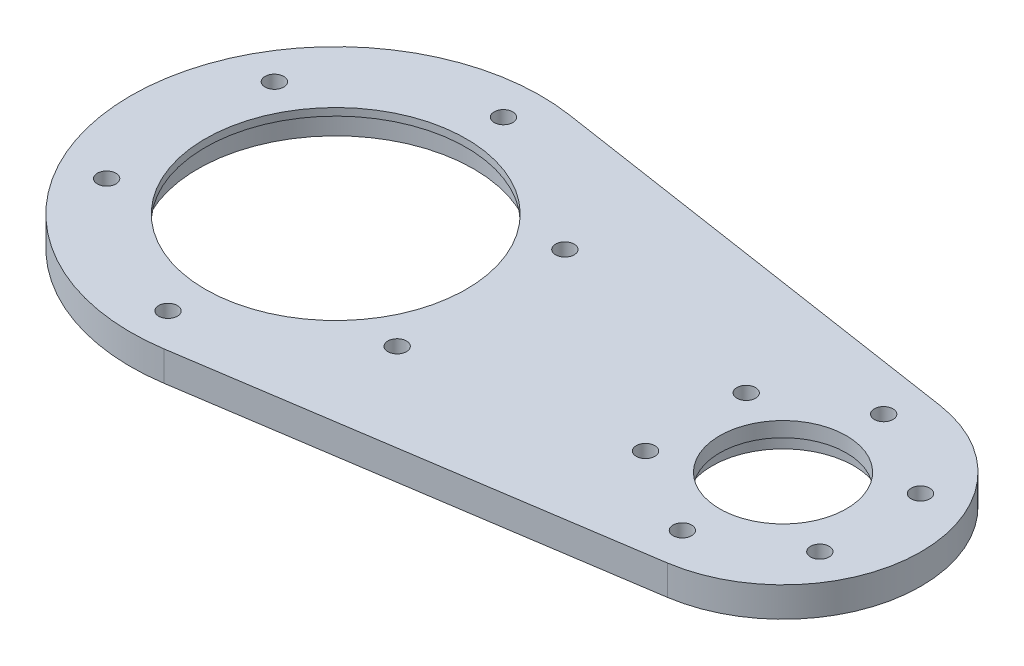
from build123d import *

# Parameters (mm, degrees)
SKETCH_1_R               = 27.5
SKETCH_1_R_2             = 17.5
EXTRUDE_1_DEPTH          = 5
SKETCH_2_R               = 27.5
SKETCH_2_R_2             = 18.5
EXTRUDE_2_DEPTH          = 5
EXTRUDE_3_DEPTH          = 9
SKETCH_7_R               = 18.5
CUT_EXTRUDE_4_DEPTH      = 4
SKETCH_13_R              = 9.5
CUT_EXTRUDE_9_DEPTH      = 7
SKETCH_14_R              = 8.5
CUT_EXTRUDE_10_DEPTH     = 3
SKETCH_26_W              = 65.286774434
SKETCH_26_H              = 14.284249769
CUT_EXTRUDE_11_DEPTH     = 1111
SKETCH_28_R              = 18.5
SKETCH_28_R_2            = 17.5
EXTRUDE_4_DEPTH          = 1
HOLE_WIZARD_M3_1_D       = 2.5
PATTERN_CIRCULAR_1_COUNT = 6
HOLE_WIZARD_M3_2_D       = 2.5
PATTERN_CIRCULAR_2_COUNT = 6


with BuildPart() as part:
    # 스케치1 → 보스-돌출1 (new body)
    with BuildSketch(Plane(origin=(0, 0, 0), x_dir=(1, 0, 0), z_dir=(0, 1, 0))):
        Circle(SKETCH_1_R)
        Circle(SKETCH_1_R_2, mode=Mode.SUBTRACT)
    extrude(amount=EXTRUDE_1_DEPTH)

    # 스케치2 → 보스-돌출2 (add)
    with BuildSketch(Plane(origin=(0, 5, 0), x_dir=(1, 0, 0), z_dir=(0, 1, 0))):
        Circle(SKETCH_2_R)
        Circle(SKETCH_2_R_2, mode=Mode.SUBTRACT)
    extrude(amount=EXTRUDE_2_DEPTH)

    # 스케치3 → 보스-돌출3 (add)
    with BuildSketch(Plane(origin=(0, 10, 0), x_dir=(1, 0, 0), z_dir=(0, 1, 0))):
        with BuildLine():
            Line((4.125, 27.188864908), (62.775, 18.290690938))
            ThreePointArc((62.775, 18.290690938), (78.5, 0), (62.775, -18.290690938))
            Line((62.775, -18.290690938), (4.125, -27.188864908))
            ThreePointArc((4.125, -27.188864908), (27.5, 0), (4.125, 27.188864908))
        make_face()
    extrude(amount=-EXTRUDE_3_DEPTH)

    # 스케치7 → 컷-돌출4 (cut)
    with BuildSketch(Plane(origin=(0, 5, 0), x_dir=(1, 0, 0), z_dir=(0, 1, 0))):
        Circle(SKETCH_7_R)
    extrude(amount=-CUT_EXTRUDE_4_DEPTH, mode=Mode.SUBTRACT)

    # 스케치13 → 컷-돌출9 (cut)
    with BuildSketch(Plane.XZ.offset(-1)):
        with Locations((60, 0)):
            Circle(SKETCH_13_R)
    extrude(amount=-CUT_EXTRUDE_9_DEPTH, mode=Mode.SUBTRACT)

    # 스케치14 → 컷-돌출10 (cut, through all)
    with BuildSketch(Plane.XZ.offset(-8)):
        with Locations((60, 0)):
            Circle(SKETCH_14_R)
    extrude(amount=-CUT_EXTRUDE_10_DEPTH, mode=Mode.SUBTRACT)

    # 스케치26 → 컷-돌출11 (cut, symmetric)
    with BuildSketch(Plane(origin=(0, 0, 0), x_dir=(0, 0, -1), z_dir=(1, 0, 0))):
        with Locations((-1.179133759, -1.142124885)):
            Rectangle(SKETCH_26_W, SKETCH_26_H)
    extrude(amount=CUT_EXTRUDE_11_DEPTH, both=True, mode=Mode.SUBTRACT)

    # 스케치28 → 보스-돌출4 (add)
    with BuildSketch(Plane(origin=(0, 10, 0), x_dir=(1, 0, 0), z_dir=(0, 1, 0))):
        Circle(SKETCH_28_R)
        Circle(SKETCH_28_R_2, mode=Mode.SUBTRACT)
    extrude(amount=-EXTRUDE_4_DEPTH)

    # M3 탭을 위한 탭 드릴1 (through all)
    with Locations(Plane(origin=(0, 6, 0), x_dir=(-1, 0, 0), z_dir=(0, -1, 0))):
        with Locations((0, 22.5)):
            hole_wizard_m3_1 = Hole(HOLE_WIZARD_M3_1_D / 2)

    # 원형 패턴1: M3 탭을 위한 탭 드릴1 ×6 about axis
    pattern_circular_1_axis = Axis((0, 0, 0), (0, 1, 0))
    for i in range(1, PATTERN_CIRCULAR_1_COUNT):
        add(hole_wizard_m3_1.rotate(pattern_circular_1_axis, i * 360 / PATTERN_CIRCULAR_1_COUNT), mode=Mode.SUBTRACT)

    # M3 탭을 위한 탭 드릴2 (through all)
    with Locations(Plane(origin=(0, 6, 0), x_dir=(-1, 0, 0), z_dir=(0, -1, 0))):
        with Locations((-60, 13.5)):
            hole_wizard_m3_2 = Hole(HOLE_WIZARD_M3_2_D / 2)

    # 원형 패턴2: M3 탭을 위한 탭 드릴2 ×6 about axis
    pattern_circular_2_axis = Axis((60, 0, 0), (0, 1, 0))
    for i in range(1, PATTERN_CIRCULAR_2_COUNT):
        add(hole_wizard_m3_2.rotate(pattern_circular_2_axis, i * 360 / PATTERN_CIRCULAR_2_COUNT), mode=Mode.SUBTRACT)


solid = part.part
